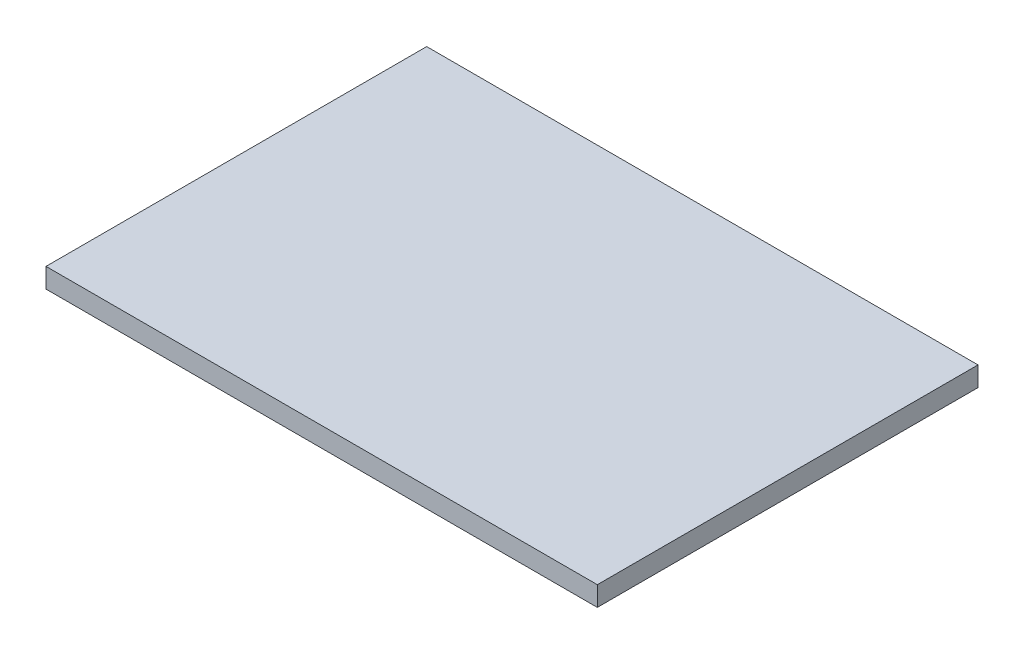
from build123d import *

# Parameters (mm, degrees)
SKETCH1_W           = 1066.8
SKETCH1_H           = 736.6
BOSS_EXTRUDE1_DEPTH = 38.1


with BuildPart() as part:
    # Sketch1 → Boss-Extrude1 (new body)
    with BuildSketch(Plane(origin=(0, 0, 0), x_dir=(1, 0, 0), z_dir=(0, 1, 0))):
        Rectangle(SKETCH1_W, SKETCH1_H)
    extrude(amount=BOSS_EXTRUDE1_DEPTH)


solid = part.part
